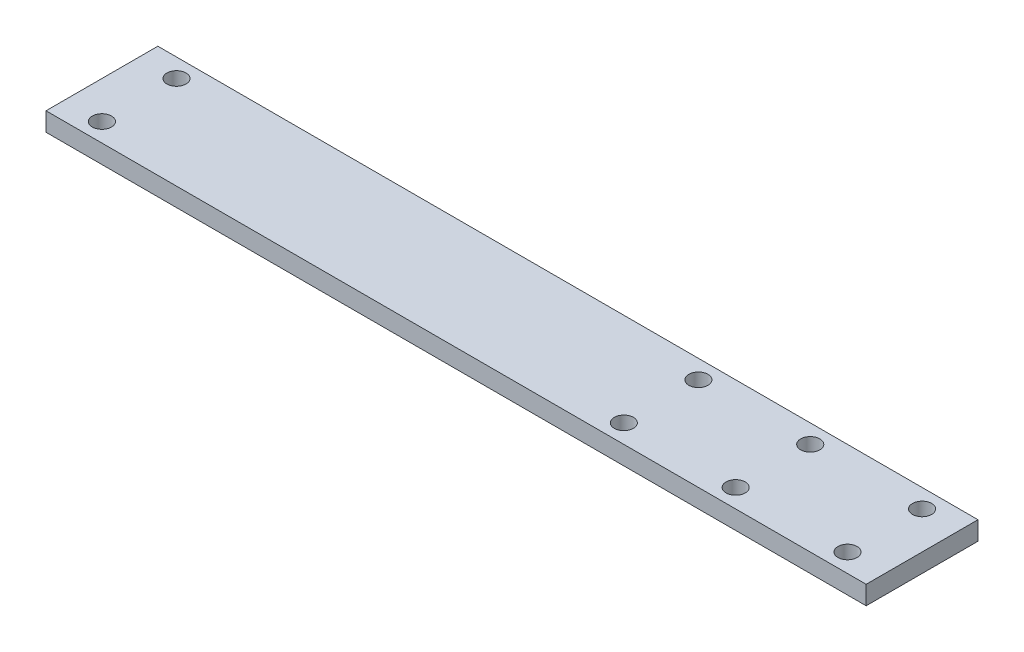
from build123d import *

# Parameters (mm, degrees)
SKETCH1_W                   = 279.4
SKETCH1_H                   = 38.1
BOSS_EXTRUDE1_DEPTH         = 6.35
F_1_4_CLEARANCE_HOLE1_D     = 6.5278
F_1_4_CLEARANCE_HOLE1_DEPTH = 6.35


with BuildPart() as part:
    # Sketch1 → Boss-Extrude1 (new body)
    with BuildSketch(Plane(origin=(0, 0, 0), x_dir=(1, 0, 0), z_dir=(0, 1, 0))):
        Rectangle(SKETCH1_W, SKETCH1_H)
    extrude(amount=BOSS_EXTRUDE1_DEPTH)

    # 1/4 Clearance Hole1
    with Locations(Plane(origin=(0, 6.35, 0), x_dir=(-1, 0, 0), z_dir=(0, 1, 0))):
        with Locations((127, 12.7), (127, -12.7), (-127, -12.7), (-127, 12.7), (-88.9, -12.7), (-88.9, 12.7), (-50.8, -12.7), (-50.8, 12.7)):
            Hole(F_1_4_CLEARANCE_HOLE1_D / 2, depth=F_1_4_CLEARANCE_HOLE1_DEPTH)


solid = part.part
